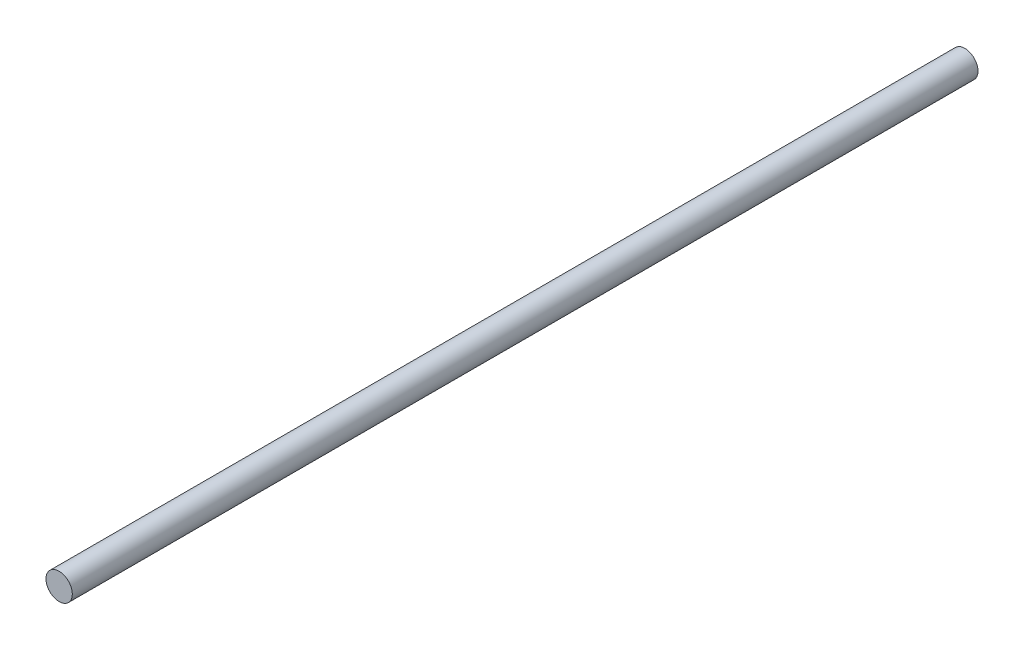
from build123d import *

# Parameters (mm, degrees)
SKETCH1_R           = 5
BOSS_EXTRUDE1_DEPTH = 344


with BuildPart() as part:
    # Sketch1 → Boss-Extrude1 (new body)
    with BuildSketch(Plane.XY):
        Circle(SKETCH1_R)
    extrude(amount=BOSS_EXTRUDE1_DEPTH)


solid = part.part
